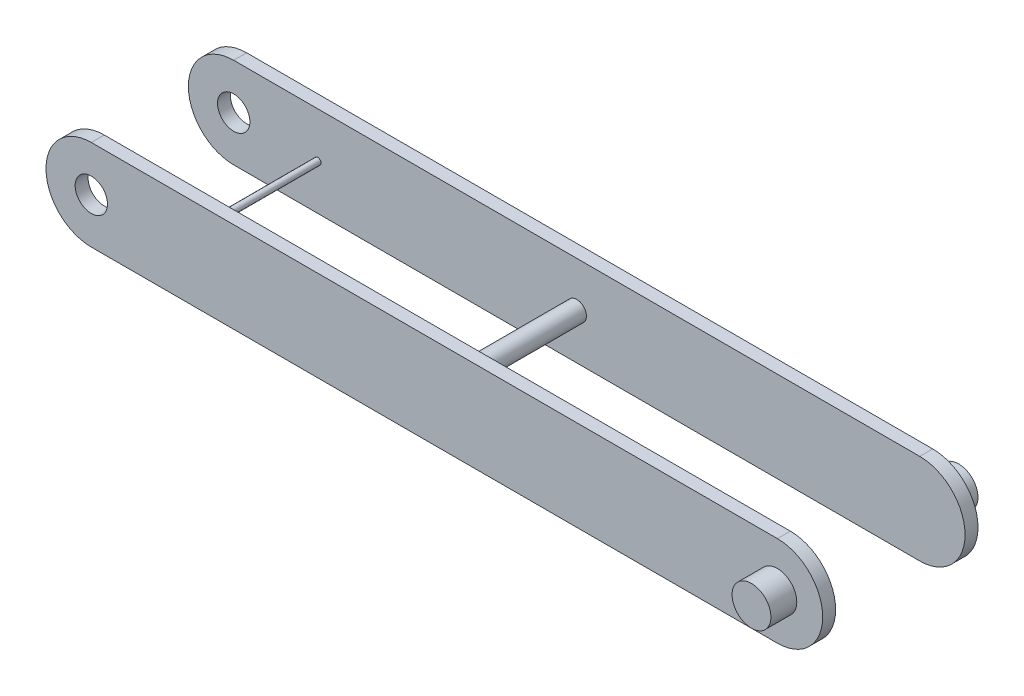
from build123d import *

# Parameters (mm, degrees)
BOSS_EXTRUDE1_DEPTH = 10
BOSS_EXTRUDE2_DEPTH = 10
SKETCH3_R           = 7.5
BOSS_EXTRUDE3_DEPTH = 145
SKETCH4_R           = 2.5
BOSS_EXTRUDE4_DEPTH = 145
SKETCH6_R           = 12.5
CUT_EXTRUDE1_DEPTH  = 165
SKETCH9_R           = 7.5
CUT_EXTRUDE2_DEPTH  = 25
SKETCH11_R          = 15
BOSS_EXTRUDE6_DEPTH = 20
SKETCH12_R          = 15
BOSS_EXTRUDE7_DEPTH = 20
SKETCH13_R          = 15
CUT_EXTRUDE6_DEPTH  = 25


with BuildPart() as part:
    # Sketch1 → Boss-Extrude1 (new body)
    with BuildSketch(Plane.XY):
        with BuildLine():
            Line((-265, 35), (265, 35))
            ThreePointArc((265, 35), (300, 0), (265, -35))
            Line((265, -35), (-265, -35))
            ThreePointArc((-265, -35), (-300, 0), (-265, 35))
        make_face()
    extrude(amount=BOSS_EXTRUDE1_DEPTH)



with BuildPart() as body_2:
    # Sketch2 → Boss-Extrude2 (new body)
    with BuildSketch(Plane.XY.offset(-100)):
        with BuildLine():
            Line((-265, 35), (265, 35))
            ThreePointArc((265, 35), (300, 0), (265, -35))
            Line((265, -35), (-265, -35))
            ThreePointArc((-265, -35), (-300, 0), (-265, 35))
        make_face()
    extrude(amount=-BOSS_EXTRUDE2_DEPTH)


with BuildPart() as part_1:
    add(part.part)

    add(body_2.part)  # Boss-Extrude3 merges body 2
    # Sketch3 → Boss-Extrude3 (add)
    with BuildSketch(Plane(origin=(0, 0, -110), x_dir=(-1, 0, 0), z_dir=(0, 0, -1))):
        Circle(SKETCH3_R)
    extrude(amount=-BOSS_EXTRUDE3_DEPTH)

    # Sketch4 → Boss-Extrude4 (add)
    with BuildSketch(Plane(origin=(0, 0, -110), x_dir=(-1, 0, 0), z_dir=(0, 0, -1))):
        with Locations((200, 0)):
            Circle(SKETCH4_R)
    extrude(amount=-BOSS_EXTRUDE4_DEPTH)

    # Sketch6 → Cut-Extrude1 (cut)
    with BuildSketch(Plane(origin=(0, 0, -110), x_dir=(-1, 0, 0), z_dir=(0, 0, -1))):
        with Locations((265, 0)):
            Circle(SKETCH6_R)
    extrude(amount=-CUT_EXTRUDE1_DEPTH, mode=Mode.SUBTRACT)

    # Sketch9 → Cut-Extrude2 (cut)
    with BuildSketch(Plane.XY.offset(35)):
        with Locations((-200, 0)):
            Circle(SKETCH9_R)
    extrude(amount=-CUT_EXTRUDE2_DEPTH, mode=Mode.SUBTRACT)

    # Sketch11 → Boss-Extrude6 (add)
    with BuildSketch(Plane.XY.offset(10)):
        with Locations((265, 0)):
            Circle(SKETCH11_R)
    extrude(amount=BOSS_EXTRUDE6_DEPTH)

    # Sketch12 → Boss-Extrude7 (add)
    with BuildSketch(Plane(origin=(0, 0, -110), x_dir=(-1, 0, 0), z_dir=(0, 0, -1))):
        with Locations((-265, 0)):
            Circle(SKETCH12_R)
    extrude(amount=BOSS_EXTRUDE7_DEPTH)

    # Sketch13 → Cut-Extrude6 (cut)
    with BuildSketch(Plane.XY.offset(35)):
        Circle(SKETCH13_R)
    extrude(amount=-CUT_EXTRUDE6_DEPTH, mode=Mode.SUBTRACT)


solid = part_1.part
